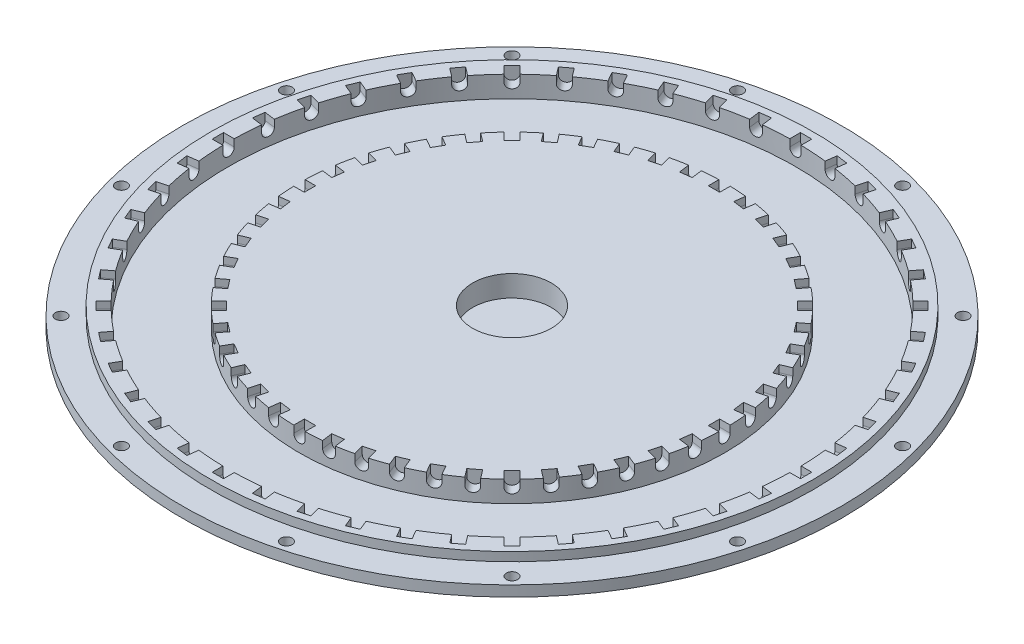
from build123d import *

# Parameters (mm, degrees)
HOLESTOFIXCYLINDER_DEPTH           = 13
ESQUISSE4_R                        = 1.6
HOLESTOFIXMAIN_DEPTH               = 7.5
HOLESTOFIXCYLINDERREPETITION_COUNT = 48
HOLESTOFIXMAINREPETITION_COUNT     = 12
ESQUISSE5_W                        = 44.9
ESQUISSE5_H                        = 6
ESQUISSE5_R                        = 1.3
REINFORCEMENT_DEPTH                = 5
REINFORCEMENTREPETITION_COUNT      = 8


with BuildPart() as part:
    # Esquisse1 → MainRevolution (revolve)
    with BuildSketch(Plane.XY):
        Polygon((-93, 3.5), (-83, 3.5), (-83, 0), (-55, 0), (-55, 6), (-14.1, 6), (-14.1, 0), (0, 0), (0, 3), (-11.1, 3), (-11.1, 9), (-60, 9), (-60, 3), (-80, 3), (-80, 9), (-85, 9), (-85, 6.5), (-93, 6.5), align=None)
    revolve(axis=Axis((0, 0, 0), (0, 1, 0)))

    # Esquisse3 → HolesToFixCylinder (cut, symmetric)
    with BuildSketch(Plane(origin=(70, 0, 0), x_dir=(0, 0, -1), z_dir=(1, 0, 0))):
        with BuildLine():
            Line((-1.6, 9), (1.6, 9))
            Line((1.6, 9), (1.6, 7.000000025))
            ThreePointArc((1.6, 7.000000025), (0, 5.4), (-1.6, 7.000000025))
            Line((-1.6, 7.000000025), (-1.6, 9))
        make_face()
    holestofixcylinder = extrude(amount=HOLESTOFIXCYLINDER_DEPTH, both=True, mode=Mode.SUBTRACT)

    # Esquisse4 → HolesToFixMain (cut, through all)
    with BuildSketch(Plane(origin=(0, 6.5, 0), x_dir=(1, 0, 0), z_dir=(0, 1, 0))):
        with Locations((86.933324366, -23.293714059)):
            Circle(ESQUISSE4_R)
    holestofixmain = extrude(amount=-HOLESTOFIXMAIN_DEPTH, mode=Mode.SUBTRACT)

    # HolesToFixCylinderRepetition: HolesToFixCylinder ×48 about axis
    holestofixcylinderrepetition_axis = Axis((0, 0, 0), (0, 1, 0))
    for i in range(1, HOLESTOFIXCYLINDERREPETITION_COUNT):
        add(holestofixcylinder.rotate(holestofixcylinderrepetition_axis, i * 360 / HOLESTOFIXCYLINDERREPETITION_COUNT), mode=Mode.SUBTRACT)

    # HolesToFixMainRepetition: HolesToFixMain ×12 about axis
    holestofixmainrepetition_axis = Axis((0, 0, 0), (0, 1, 0))
    for i in range(1, HOLESTOFIXMAINREPETITION_COUNT):
        add(holestofixmain.rotate(holestofixmainrepetition_axis, i * 360 / HOLESTOFIXMAINREPETITION_COUNT), mode=Mode.SUBTRACT)

    # Esquisse5 → Reinforcement (add, symmetric)
    with BuildSketch(Plane.XY):
        with Locations((33.55, 3)):
            Rectangle(ESQUISSE5_W, ESQUISSE5_H)
        with Locations((21.1, 3)):
            Circle(ESQUISSE5_R, mode=Mode.SUBTRACT)
        with Locations((31.1, 3)):
            Circle(ESQUISSE5_R, mode=Mode.SUBTRACT)
        with Locations((41.1, 3)):
            Circle(ESQUISSE5_R, mode=Mode.SUBTRACT)
    reinforcement = extrude(amount=REINFORCEMENT_DEPTH, both=True)

    # ReinforcementRepetition: Reinforcement ×8 about axis, 4 skipped
    reinforcementrepetition_axis = Axis((0, 8.925, 0), (0, -1, 0))
    add([reinforcement.rotate(reinforcementrepetition_axis, i * 360 / REINFORCEMENTREPETITION_COUNT) for i in range(1, REINFORCEMENTREPETITION_COUNT) if i not in (1, 3, 5, 7)])


solid = part.part
